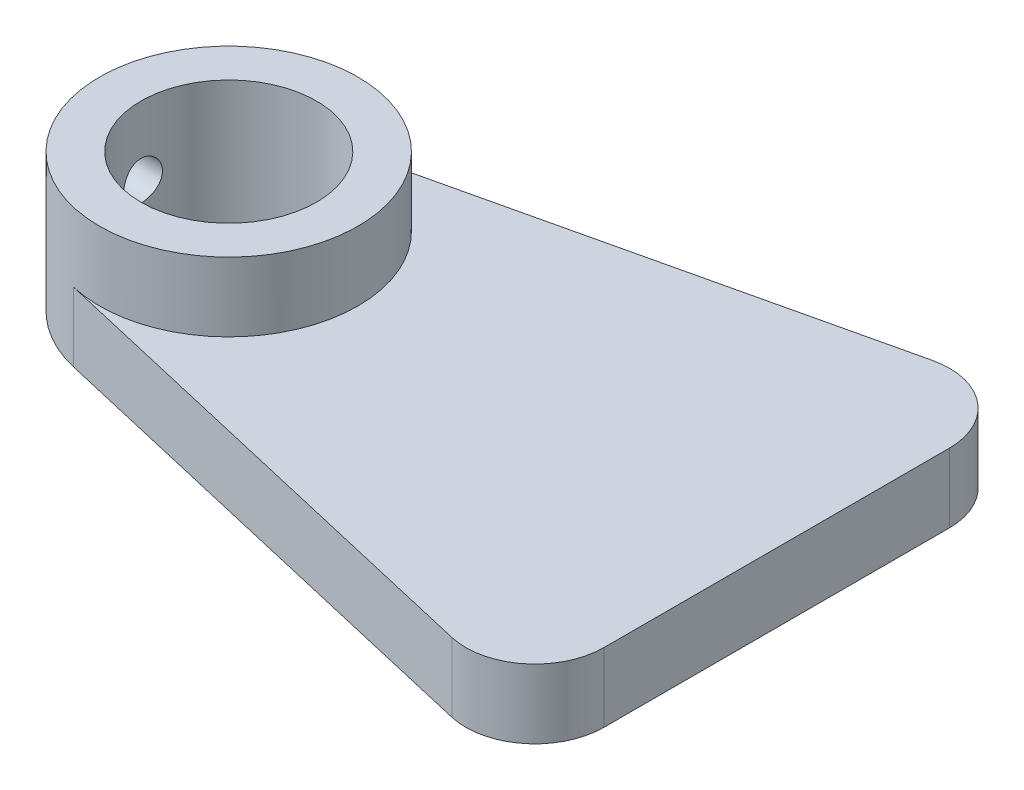
from build123d import *

# Parameters (mm, degrees)
SKETCH1_R           = 6.35
BOSS_EXTRUDE1_DEPTH = 5
SKETCH1_3_R         = 6.35
BOSS_EXTRUDE2_DEPTH = 10
SKETCH2_R           = 1.4
CUT_EXTRUDE1_DEPTH  = 45.478899492


with BuildPart() as part:
    # Sketch1 → Boss-Extrude1 (new body)
    with BuildSketch(Plane(origin=(0, 0, 0), x_dir=(1, 0, 0), z_dir=(0, 1, 0))):
        with BuildLine():
            Line((33.520573743, 17.370769583), (-2.1120271, 9.10833912))
            ThreePointArc((-2.1120271, 9.10833912), (-9.35, 0), (-2.1120271, -9.10833912))
            Line((-2.1120271, -9.10833912), (33.520573743, -17.370769583))
            ThreePointArc((33.520573743, -17.370769583), (37.760696764, -16.414532621), (39.65, -12.5))
            Line((39.65, -12.5), (39.65, 12.5))
            ThreePointArc((39.65, 12.5), (37.760696764, 16.414532621), (33.520573743, 17.370769583))
        make_face()
        Circle(SKETCH1_R, mode=Mode.SUBTRACT)
    extrude(amount=BOSS_EXTRUDE1_DEPTH)

    # Sketch1_3 → Boss-Extrude2 (add)
    with BuildSketch(Plane(origin=(0, 0, 0), x_dir=(1, 0, 0), z_dir=(0, 1, 0))):
        with BuildLine():
            ThreePointArc((9.35, 0), (5.817002949, 7.320176001), (-2.1120271, 9.10833912))
            ThreePointArc((-2.1120271, 9.10833912), (-9.35, 0), (-2.1120271, -9.10833912))
            ThreePointArc((-2.1120271, -9.10833912), (5.817002949, -7.320176001), (9.35, 0))
        make_face()
        Circle(SKETCH1_3_R, mode=Mode.SUBTRACT)
    extrude(amount=BOSS_EXTRUDE2_DEPTH)

    # Sketch2 → Cut-Extrude1 (cut, through all)
    with BuildSketch(Plane(origin=(0, 0, 0), x_dir=(0, 0, -1), z_dir=(1, 0, 0))):
        with Locations((0, 5)):
            Circle(SKETCH2_R)
    extrude(amount=-CUT_EXTRUDE1_DEPTH, mode=Mode.SUBTRACT)


solid = part.part
